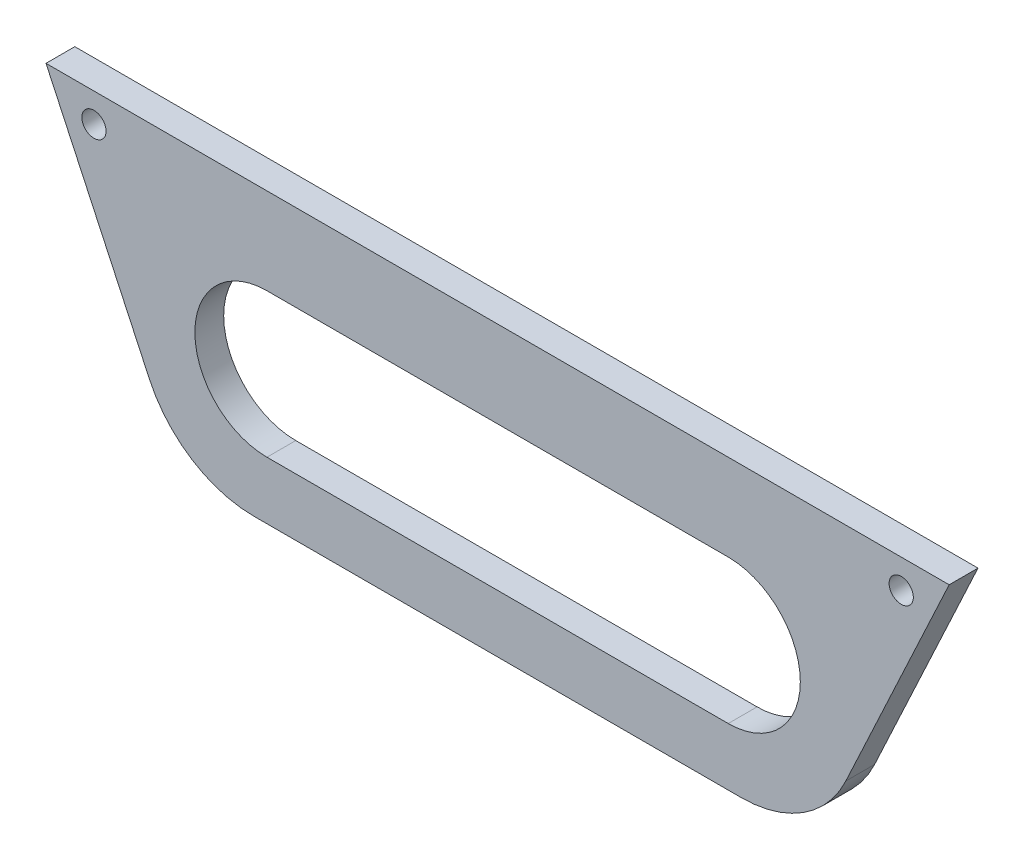
from build123d import *

# Parameters (mm, degrees)
SKETCH1_R           = 2.1
BOSS_EXTRUDE1_DEPTH = 5


with BuildPart() as part:
    # Sketch1 → Boss-Extrude1 (new body)
    with BuildSketch(Plane.XY):
        with BuildLine():
            Line((156.630765815, 0), (0, 0))
            Line((0, 0), (17.930632383, -38.452365235))
            ThreePointArc((17.930632383, -38.452365235), (25.310795957, -46.867828916), (36.056788124, -50))
            Line((36.056788124, -50), (120.573977692, -50))
            ThreePointArc((120.573977692, -50), (131.319969859, -46.867828916), (138.700133432, -38.452365235))
            Line((138.700133432, -38.452365235), (156.630765815, 0))
        make_face()
        with Locations((148.315382907, -5)):
            Circle(SKETCH1_R, mode=Mode.SUBTRACT)
        with Locations((8.315382909, -5)):
            Circle(SKETCH1_R, mode=Mode.SUBTRACT)
        with BuildLine():
            Line((118.315382908, -15), (38.315382908, -15))
            ThreePointArc((38.315382908, -15), (25.815382908, -27.5), (38.315382908, -40))
            Line((38.315382908, -40), (118.315382908, -40))
            ThreePointArc((118.315382908, -40), (130.815382908, -27.5), (118.315382908, -15))
        make_face(mode=Mode.SUBTRACT)
    extrude(amount=BOSS_EXTRUDE1_DEPTH)


solid = part.part
